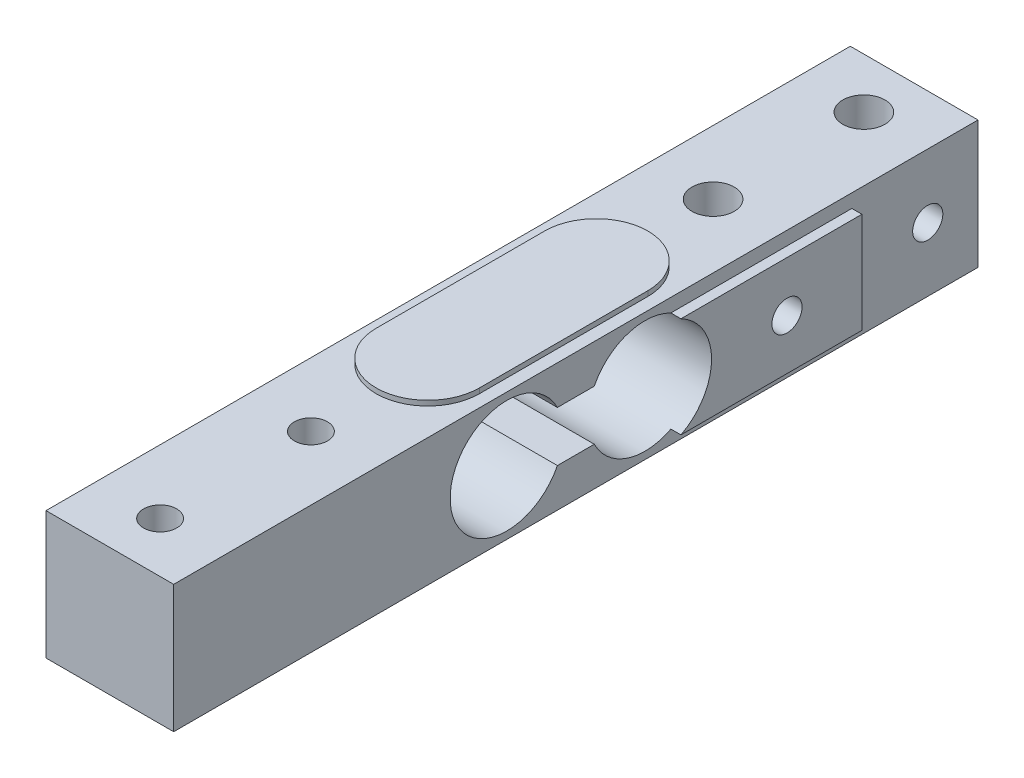
from build123d import *

# Parameters (mm, degrees)
SKETCH1_W               = 80
SKETCH1_H               = 12.7
BOSS_EXTRUDE1_DEPTH     = 6.35
CUT_EXTRUDE1_DEPTH      = 41.995670503
CUT_EXTRUDE1_DEPTH_BACK = 41.995670503
SKETCH2_R               = 5.625
CUT_EXTRUDE2_DEPTH      = 41.995670503
CUT_EXTRUDE2_DEPTH_BACK = 41.995670503
SKETCH3_W               = 23.827822186
SKETCH3_H               = 5
M4X0_7_TAPPED_HOLE1_D   = 3.3
GOO_DEPTH               = 0.5
BOSS_EXTRUDE5_DEPTH     = 1
F_3_0MM_DOWEL_HOLE1_D   = 3
M5X0_8_TAPPED_HOLE1_D   = 4.2


with BuildPart() as part:
    # Sketch1 → Boss-Extrude1 (new, symmetric)
    with BuildSketch(Plane(origin=(0, 0, 0), x_dir=(0, 0, -1), z_dir=(1, 0, 0))):
        Rectangle(SKETCH1_W, SKETCH1_H)
    extrude(amount=BOSS_EXTRUDE1_DEPTH, both=True)

    # Sketch2 → Cut-Extrude1 (cut, two sides: drawn at the far end of the back side and taken through both)
    with BuildSketch(Plane(origin=(0, 0, 0), x_dir=(0, 0, -1), z_dir=(1, 0, 0)).offset(-CUT_EXTRUDE1_DEPTH_BACK)):
        with Locations((-6.875, 0)):
            Circle(SKETCH2_R)
        with Locations((6.875, 0)):
            Circle(SKETCH2_R)
    extrude(amount=CUT_EXTRUDE1_DEPTH + CUT_EXTRUDE1_DEPTH_BACK, mode=Mode.SUBTRACT)

    # Sketch3 → Cut-Extrude2 (cut, two sides: drawn at the far end of the back side and taken through both)
    with BuildSketch(Plane(origin=(0, 0, 0), x_dir=(0, 0, -1), z_dir=(1, 0, 0)).offset(-CUT_EXTRUDE2_DEPTH_BACK)):
        Rectangle(SKETCH3_W, SKETCH3_H)
    extrude(amount=CUT_EXTRUDE2_DEPTH + CUT_EXTRUDE2_DEPTH_BACK, mode=Mode.SUBTRACT)

    # M4x0.7 Tapped Hole1 (through all)
    with Locations(Plane(origin=(0, 6.35, 0), x_dir=(1, 0, 0), z_dir=(0, 1, 0))):
        with Locations((0, 35), (0, 20), (0, -20), (0, -35)):
            Hole(M4X0_7_TAPPED_HOLE1_D / 2)

    # Sketch8 → Goo (add, symmetric)
    with BuildSketch(Plane(origin=(0, 6.35, 0), x_dir=(1, 0, 0), z_dir=(0, 1, 0))):
        with BuildLine():
            Line((-5.13731221, -8.377770681), (-5.13731221, 8.377770681))
            ThreePointArc((-5.13731221, 8.377770681), (0, 13.515082891), (5.13731221, 8.377770681))
            Line((5.13731221, 8.377770681), (5.13731221, -8.377770681))
            ThreePointArc((5.13731221, -8.377770681), (0, -13.515082891), (-5.13731221, -8.377770681))
        make_face()
    goo = extrude(amount=GOO_DEPTH, both=True)

    # Mirror1: Goo across plane
    add(goo.mirror(Plane.ZX))

    # Sketch9 → Boss-Extrude5 (add, symmetric)
    with BuildSketch(Plane(origin=(6.35, 0, 0), x_dir=(0, 0, -1), z_dir=(1, 0, 0))):
        with BuildLine():
            Line((9.451941016, -5), (27.451941016, -5))
            Line((27.451941016, -5), (27.451941016, 5))
            Line((27.451941016, 5), (9.451941016, 5))
            ThreePointArc((9.451941016, 5), (12.5, 0), (9.451941016, -5))
        make_face()
    extrude(amount=BOSS_EXTRUDE5_DEPTH, both=True)

    # Ø3.0mm Dowel Hole1 (through all)
    with Locations(Plane.ZY.offset(6.35)):
        with Locations((-20, 0), (-35, 0)):
            Hole(F_3_0MM_DOWEL_HOLE1_D / 2)

    # M5x0.8 Tapped Hole1 (through all)
    with Locations(Plane(origin=(0, 6.35, 0), x_dir=(1, 0, 0), z_dir=(0, 1, 0))):
        with Locations((0, 35), (0, 20)):
            Hole(M5X0_8_TAPPED_HOLE1_D / 2)


solid = part.part
